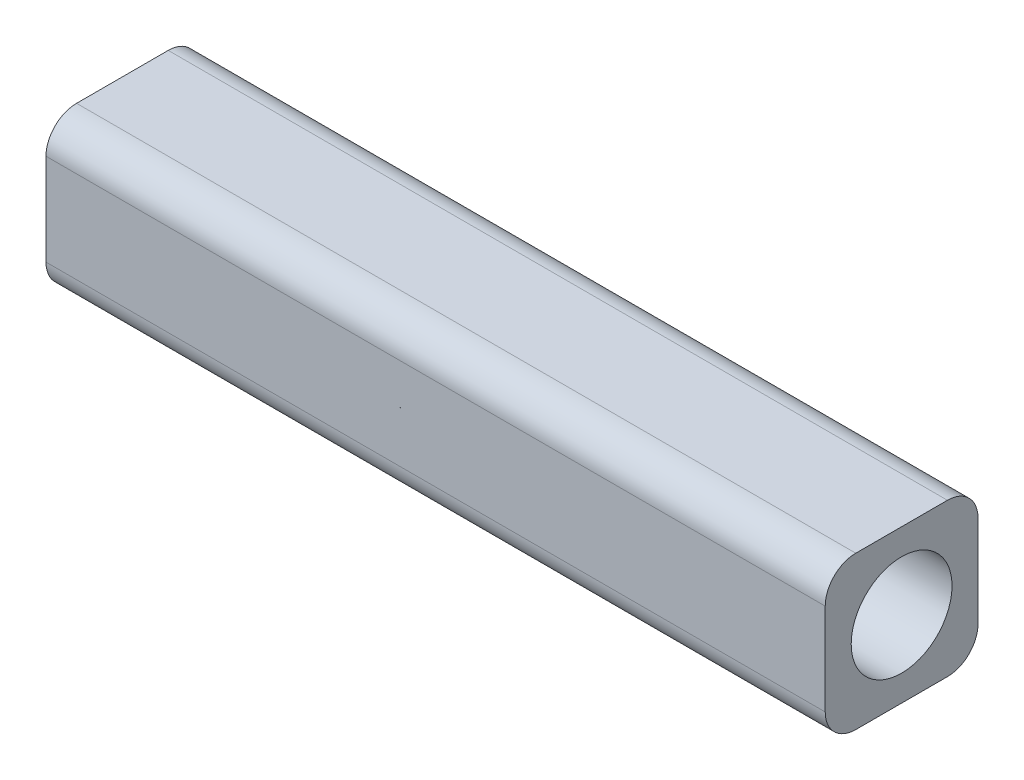
from build123d import *

# Parameters (mm, degrees)
SKETCH1_W               = 25.5
SKETCH1_H               = 5
BOSS_EXTRUDE1_DEPTH     = 5
SKETCH2_R               = 1.65
CUT_EXTRUDE1_DEPTH      = 1
CUT_EXTRUDE1_DEPTH_BACK = 26.5
FILLET1_R               = 1


with BuildPart() as part:
    # Sketch1 → Boss-Extrude1 (new body)
    with BuildSketch(Plane(origin=(0, 0, 0), x_dir=(1, 0, 0), z_dir=(0, 1, 0))):
        Rectangle(SKETCH1_W, SKETCH1_H)
    extrude(amount=BOSS_EXTRUDE1_DEPTH)

    # Sketch2 → Cut-Extrude1 (cut, two sides)
    with BuildSketch(Plane(origin=(12.75, 0, 0), x_dir=(0, 0, -1), z_dir=(1, 0, 0))) as cut_extrude1_sk:
        with Locations((0, 2.5)):
            Circle(SKETCH2_R)
    extrude(amount=CUT_EXTRUDE1_DEPTH, mode=Mode.SUBTRACT)
    extrude(cut_extrude1_sk.sketch, amount=-CUT_EXTRUDE1_DEPTH_BACK, mode=Mode.SUBTRACT)

    # Fillet1
    fillet1_edges = [part.edges().sort_by_distance(p)[0] for p in [
        (0, 5, 2.5),
        (0, 0, 2.5),
        (0, 0, -2.5),
        (0, 5, -2.5),
    ]]
    fillet(fillet1_edges, radius=FILLET1_R)


solid = part.part
